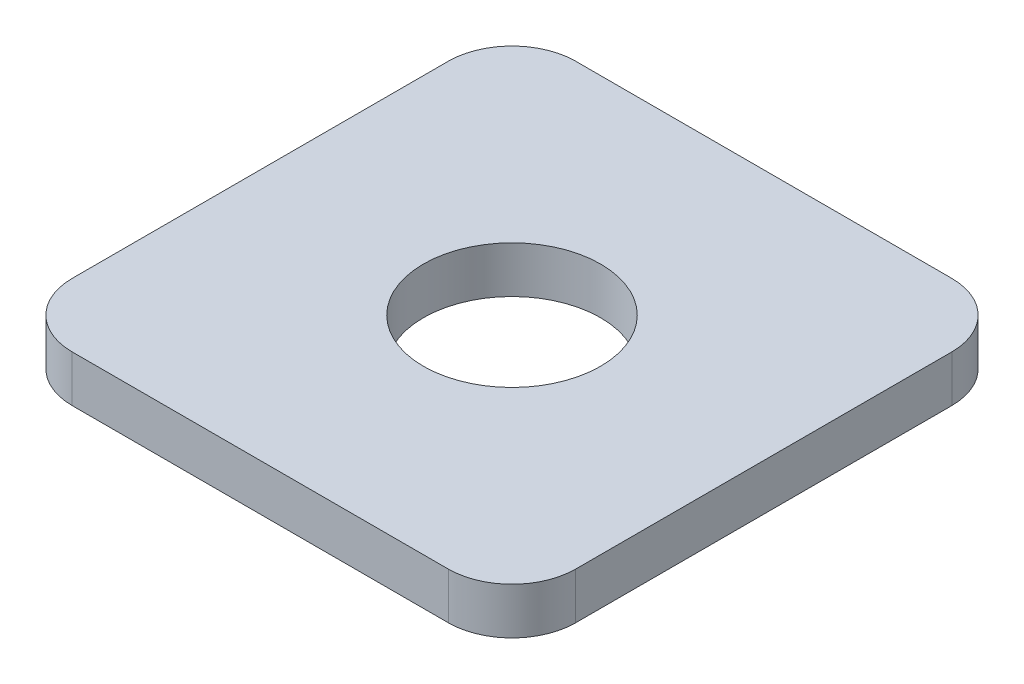
from build123d import *

# Parameters (mm, degrees)
SKETCH1_W           = 39.5
SKETCH1_H           = 39.5
SKETCH1_R           = 6.95
BOSS_EXTRUDE1_DEPTH = 3.65
FILLET1_R           = 5


with BuildPart() as part:
    # Sketch1 → Boss-Extrude1 (new body)
    with BuildSketch(Plane(origin=(0, 0, 0), x_dir=(1, 0, 0), z_dir=(0, 1, 0))):
        Rectangle(SKETCH1_W, SKETCH1_H)
        Circle(SKETCH1_R, mode=Mode.SUBTRACT)
    extrude(amount=BOSS_EXTRUDE1_DEPTH)

    # Fillet1
    fillet1_edges = [part.edges().sort_by_distance(p)[0] for p in [
        (-19.75, 1.825, -19.75),
        (19.75, 1.825, -19.75),
        (19.75, 1.825, 19.75),
        (-19.75, 1.825, 19.75),
    ]]
    fillet(fillet1_edges, radius=FILLET1_R)


solid = part.part
